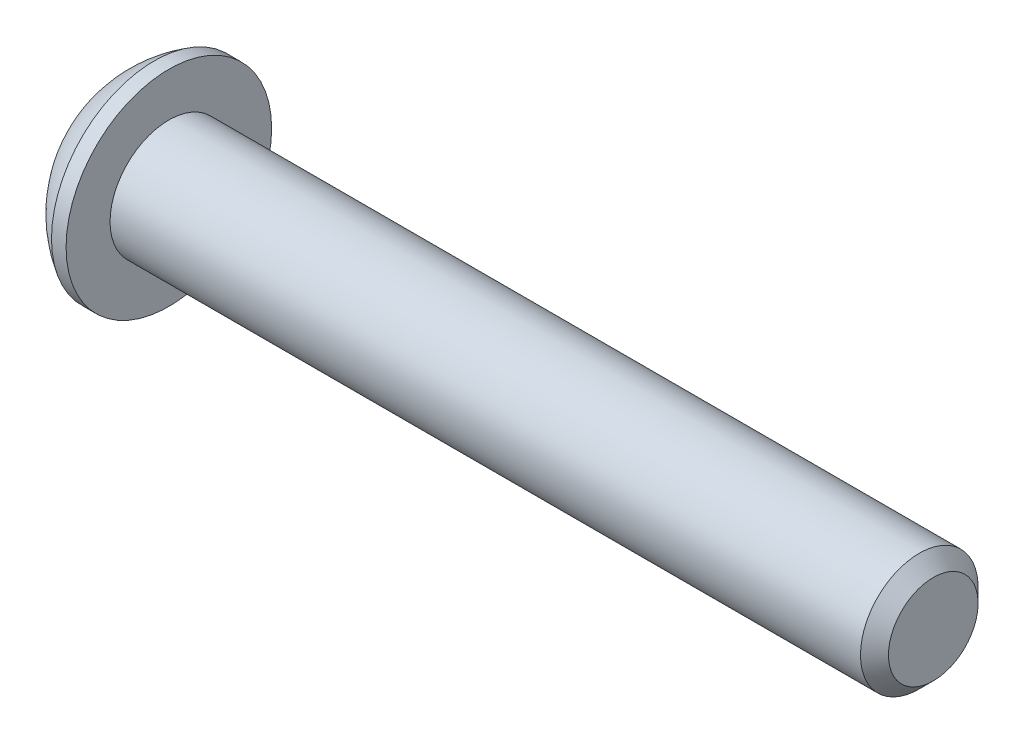
from build123d import *

# Parameters (mm, degrees)
HEX_2_DEPTH = 2.2098


with BuildPart() as part:
    # BodySke → BaseBody (revolve)
    with BuildSketch(Plane.XY):
        with BuildLine():
            Line((44.6278, 0), (44.6278, 2.41935))
            Line((44.6278, 2.41935), (43.87215, 3.175))
            Line((43.87215, 3.175), (3.3528, 3.175))
            Line((3.3528, 3.175), (3.3528, 5.5499))
            Line((3.3528, 5.5499), (2.5654, 5.5499))
            ThreePointArc((2.5654, 5.5499), (1.073764503, 4.355582759), (0, 2.77495))
            Line((0, 2.77495), (0, 0))
            Line((0, 0), (44.6278, 0))
        make_face()
    revolve(axis=Axis((0, 0, 0), (1, 0, 0)))

    # Sketch2 → PreBroach (revolve, cut)
    with BuildSketch(Plane.XY):
        Polygon((0, 1.9812), (2.2098, 1.9812), (3.353646353, 0), (0, 0), align=None)
    revolve(axis=Axis((0, 0, 0), (1, 0, 0)), mode=Mode.SUBTRACT)

    # Sketch3 → Hex 2 (cut)
    with BuildSketch(Plane(origin=(0, 0, 0), x_dir=(0, 0, -1), z_dir=(1, 0, 0))):
        Polygon((-1.9812, -1.143846353), (-1.9812, 1.143846353), (0, 2.287692707), (1.9812, 1.143846353), (1.9812, -1.143846353), (0, -2.287692707), align=None)
    extrude(amount=HEX_2_DEPTH, mode=Mode.SUBTRACT)


solid = part.part
